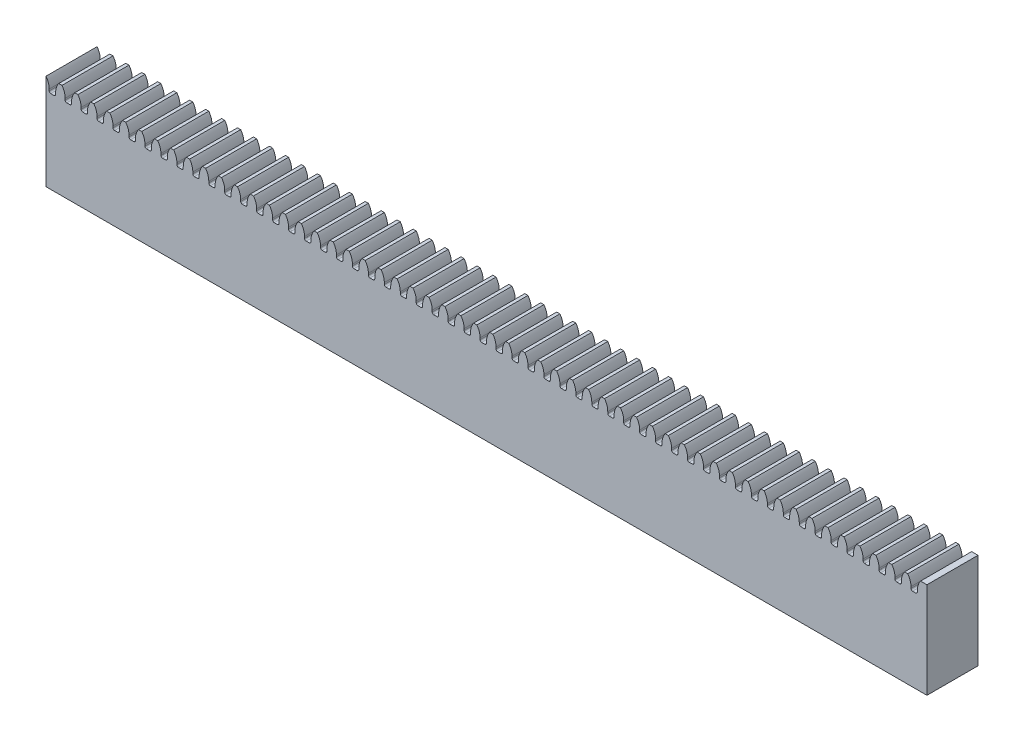
from build123d import *

# Parameters (mm, degrees)
ESQUISSE1_W                      = 138
ESQUISSE1_H                      = 8
EXTRUSION1_DEPTH                 = 15
EXTRUSION2_DEPTH                 = 8
CONG_2_R                         = 0.25
R_P_TITION_LIN_AIRE2_COUNT       = 55
R_P_TITION_LIN_AIRE2_PITCH       = 2.5
CONG_2_OF_R_P_TITION_LIN_AIRE2_R = 0.25


with BuildPart() as part:
    # Esquisse1 → Extrusion1 (new body)
    with BuildSketch(Plane(origin=(0, 0, 0), x_dir=(1, 0, 0), z_dir=(0, 1, 0))):
        with Locations((69, 4)):
            Rectangle(ESQUISSE1_W, ESQUISSE1_H)
    extrude(amount=EXTRUSION1_DEPTH)

    # Esquisse2 → Extrusion2 (cut)
    with BuildSketch(Plane.XY):
        with BuildLine():
            Line((0, 15), (2, 15))
            ThreePointArc((2, 15), (1.628291755, 14.290569415), (1.5, 13.5))
            Line((1.5, 13.5), (1.5, 13))
            Line((1.5, 13), (0.5, 13))
            Line((0.5, 13), (0.5, 13.5))
            ThreePointArc((0.5, 13.5), (0.371708245, 14.290569415), (0, 15))
        make_face()
    extrusion2 = extrude(amount=-EXTRUSION2_DEPTH, mode=Mode.SUBTRACT)

    # Congé2
    cong_2_edges = [part.edges().sort_by_distance(p)[0] for p in [
        (1.5, 13, -4),
        (0.5, 13, -4),
    ]]
    fillet(cong_2_edges, radius=CONG_2_R)

    # Répétition linéaire2: Extrusion2 ×55
    with Locations(*[(i * R_P_TITION_LIN_AIRE2_PITCH, 0, 0) for i in range(1, R_P_TITION_LIN_AIRE2_COUNT)]):
        add(extrusion2, mode=Mode.SUBTRACT)

    # Congé2 of Répétition linéaire2
    cong_2_of_r_p_tition_lin_aire2_edges = [part.edges().sort_by_distance(p)[0] for p in [
        (4, 13, -4),
        (3, 13, -4),
        (6.5, 13, -4),
        (5.5, 13, -4),
        (9, 13, -4),
        (8, 13, -4),
        (11.5, 13, -4),
        (10.5, 13, -4),
        (14, 13, -4),
        (13, 13, -4),
        (16.5, 13, -4),
        (15.5, 13, -4),
        (19, 13, -4),
        (18, 13, -4),
        (21.5, 13, -4),
        (20.5, 13, -4),
        (24, 13, -4),
        (23, 13, -4),
        (26.5, 13, -4),
        (25.5, 13, -4),
        (29, 13, -4),
        (28, 13, -4),
        (31.5, 13, -4),
        (30.5, 13, -4),
        (34, 13, -4),
        (33, 13, -4),
        (36.5, 13, -4),
        (35.5, 13, -4),
        (39, 13, -4),
        (38, 13, -4),
        (41.5, 13, -4),
        (40.5, 13, -4),
        (44, 13, -4),
        (43, 13, -4),
        (46.5, 13, -4),
        (45.5, 13, -4),
        (49, 13, -4),
        (48, 13, -4),
        (51.5, 13, -4),
        (50.5, 13, -4),
        (54, 13, -4),
        (53, 13, -4),
        (56.5, 13, -4),
        (55.5, 13, -4),
        (59, 13, -4),
        (58, 13, -4),
        (61.5, 13, -4),
        (60.5, 13, -4),
        (64, 13, -4),
        (63, 13, -4),
        (66.5, 13, -4),
        (65.5, 13, -4),
        (69, 13, -4),
        (68, 13, -4),
        (71.5, 13, -4),
        (70.5, 13, -4),
        (74, 13, -4),
        (73, 13, -4),
        (76.5, 13, -4),
        (75.5, 13, -4),
        (79, 13, -4),
        (78, 13, -4),
        (81.5, 13, -4),
        (80.5, 13, -4),
        (84, 13, -4),
        (83, 13, -4),
        (86.5, 13, -4),
        (85.5, 13, -4),
        (89, 13, -4),
        (88, 13, -4),
        (91.5, 13, -4),
        (90.5, 13, -4),
        (94, 13, -4),
        (93, 13, -4),
        (96.5, 13, -4),
        (95.5, 13, -4),
        (99, 13, -4),
        (98, 13, -4),
        (101.5, 13, -4),
        (100.5, 13, -4),
        (104, 13, -4),
        (103, 13, -4),
        (106.5, 13, -4),
        (105.5, 13, -4),
        (109, 13, -4),
        (108, 13, -4),
        (111.5, 13, -4),
        (110.5, 13, -4),
        (114, 13, -4),
        (113, 13, -4),
        (116.5, 13, -4),
        (115.5, 13, -4),
        (119, 13, -4),
        (118, 13, -4),
        (121.5, 13, -4),
        (120.5, 13, -4),
        (124, 13, -4),
        (123, 13, -4),
        (126.5, 13, -4),
        (125.5, 13, -4),
        (129, 13, -4),
        (128, 13, -4),
        (131.5, 13, -4),
        (130.5, 13, -4),
        (134, 13, -4),
        (133, 13, -4),
        (136.5, 13, -4),
        (135.5, 13, -4),
    ]]
    fillet(cong_2_of_r_p_tition_lin_aire2_edges, radius=CONG_2_OF_R_P_TITION_LIN_AIRE2_R)


solid = part.part
